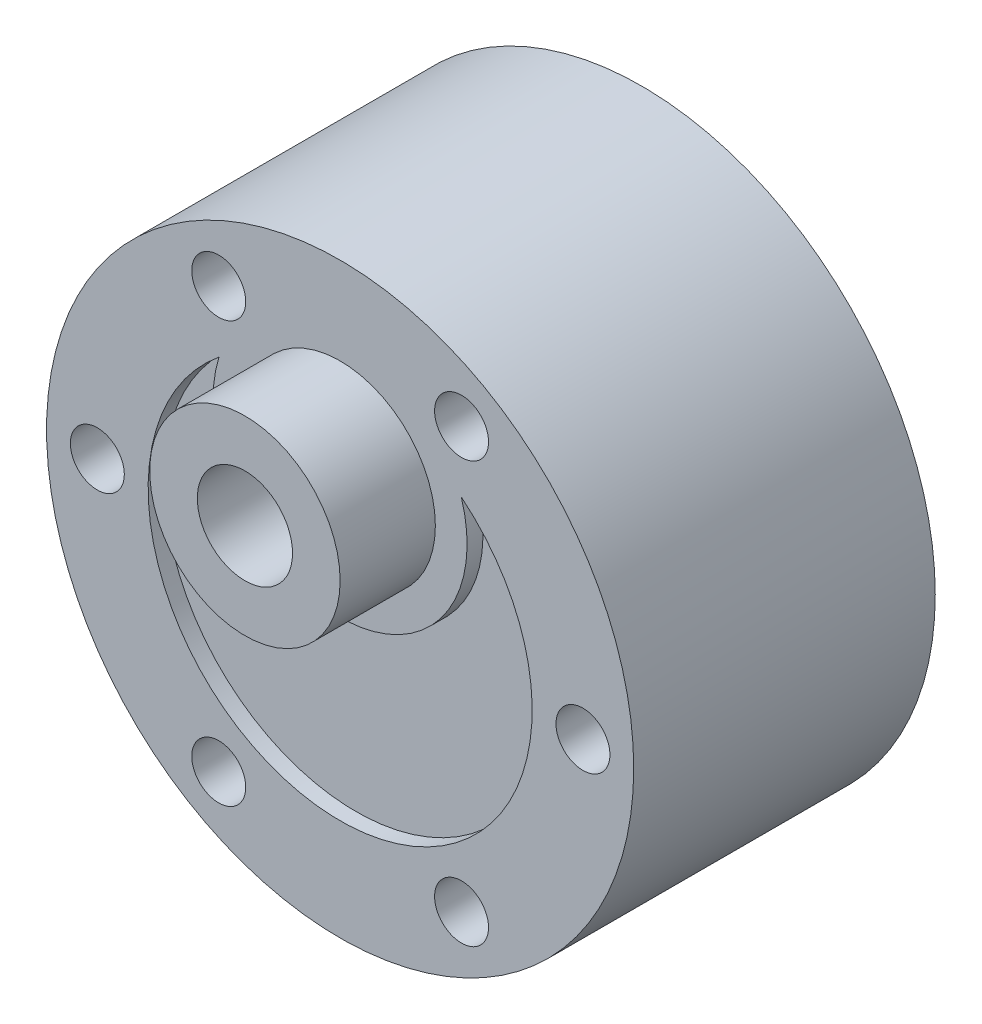
from build123d import *

# Parameters (mm, degrees)
SKETCH1_R                        = 18.5
BOSS_EXTRUDE1_DEPTH              = 19
SKETCH4_R                        = 6
BOSS_EXTRUDE4_DEPTH              = 6
CUT_EXTRUDE2_DEPTH               = 1
TALADRO_DE_MARGEN_PARA_M31_D     = 3.4
TALADRO_DE_MARGEN_PARA_M31_DEPTH = 6
TALADRO_DE_MARGEN_PARA_M31_TIP   = 1.021463052
CROQUIS1_R                       = 18
CORTAR_EXTRUIR2_DEPTH            = 12
CORTAR_EXTRUIR3_REACH            = 27
CROQUIS2_R                       = 3
CROQUIS2_R_2                     = 1.7
CROQUIS3_R                       = 18
SALIENTE_EXTRUIR1_DEPTH          = 0.5
SKETCH11_R                       = 2
CUT_EXTRUDE3_DEPTH               = 10
SKETCH12_W                       = 12.5
SKETCH12_H                       = 1.5
CUT_EXTRUDE4_DEPTH               = 0.15
SKETCH13_R                       = 6
CUT_EXTRUDE5_DEPTH               = 10
SKETCH14_R                       = 2.25
SKETCH14_R_2                     = 2
BOSS_EXTRUDE5_DEPTH              = 1


with BuildPart() as part:
    # Sketch1 → Boss-Extrude1 (new body)
    with BuildSketch(Plane.XY):
        Circle(SKETCH1_R)
    extrude(amount=BOSS_EXTRUDE1_DEPTH)

    # Sketch4 → Boss-Extrude4 (add)
    with BuildSketch(Plane.XY.offset(19)):
        with Locations((0, 7)):
            Circle(SKETCH4_R)
    extrude(amount=BOSS_EXTRUDE4_DEPTH)

    # Sketch8 → Cut-Extrude2 (cut)
    with BuildSketch(Plane.XY.offset(19)):
        with BuildLine():
            ThreePointArc((7.635768375, 9.386428571), (0, -12.1), (-7.635768375, 9.386428571))
            ThreePointArc((-7.635768375, 9.386428571), (0, -1), (7.635768375, 9.386428571))
        make_face()
    extrude(amount=-CUT_EXTRUDE2_DEPTH, mode=Mode.SUBTRACT)

    # Taladro de margen para M31
    with Locations(Plane.XY.offset(19)):
        with Locations((7.65, -13.250188678), (-7.65, -13.250188678), (-15.3, 0), (-7.65, 13.250188678), (15.3, 0), (7.65, 13.250188678)):
            Hole(TALADRO_DE_MARGEN_PARA_M31_D / 2, depth=TALADRO_DE_MARGEN_PARA_M31_DEPTH)
            with Locations((0, 0, -(TALADRO_DE_MARGEN_PARA_M31_DEPTH + TALADRO_DE_MARGEN_PARA_M31_TIP / 2))):  # 118° drill point
                Cone(0, TALADRO_DE_MARGEN_PARA_M31_D / 2, TALADRO_DE_MARGEN_PARA_M31_TIP, mode=Mode.SUBTRACT)

    # Croquis1 → Cortar-Extruir2 (cut)
    with BuildSketch(Plane(origin=(0, 0, 0), x_dir=(-1, 0, 0), z_dir=(0, 0, -1))):
        Circle(CROQUIS1_R)
    extrude(amount=-CORTAR_EXTRUIR2_DEPTH, mode=Mode.SUBTRACT)

    # Croquis2 → Cortar-Extruir3 (cut, up to next)
    with BuildSketch(Plane.XY.offset(25), mode=Mode.PRIVATE) as cortar_extruir3_sk1:
        with Locations((0, 7)):
            Circle(CROQUIS2_R)
    cortar_extruir3_tool1 = extrude(cortar_extruir3_sk1.sketch, amount=-CORTAR_EXTRUIR3_REACH, mode=Mode.PRIVATE) & part.part
    add(cortar_extruir3_tool1.solids().sort_by_distance((0, 7, 25))[0], mode=Mode.SUBTRACT)
    # Croquis2 → Cortar-Extruir3 (cut, up to next)
    with BuildSketch(Plane.XY.offset(25), mode=Mode.PRIVATE) as cortar_extruir3_sk2:
        with Locations((7.65, 13.250188678)):
            Circle(CROQUIS2_R_2)
    cortar_extruir3_tool2 = extrude(cortar_extruir3_sk2.sketch, amount=-CORTAR_EXTRUIR3_REACH, mode=Mode.PRIVATE) & part.part
    add(cortar_extruir3_tool2.solids().sort_by_distance((7.65, 13.250189, 25))[0], mode=Mode.SUBTRACT)

    # Croquis3 → Saliente-Extruir1 (add)
    with BuildSketch(Plane(origin=(0, 0, 0), x_dir=(-1, 0, 0), z_dir=(0, 0, -1))):
        Circle(CROQUIS3_R)
    extrude(amount=-SALIENTE_EXTRUIR1_DEPTH)

    # Sketch11 → Cut-Extrude3 (cut)
    with BuildSketch(Plane(origin=(0, 0, 0), x_dir=(-1, 0, 0), z_dir=(0, 0, -1))):
        Circle(SKETCH11_R)
    extrude(amount=-CUT_EXTRUDE3_DEPTH, mode=Mode.SUBTRACT)

    # Sketch12 → Cut-Extrude4 (cut)
    with BuildSketch(Plane(origin=(0, 0, 0), x_dir=(-1, 0, 0), z_dir=(0, 0, -1))):
        with Locations((0, -15)):
            Rectangle(SKETCH12_W, SKETCH12_H)
    extrude(amount=-CUT_EXTRUDE4_DEPTH, mode=Mode.SUBTRACT)

    # Sketch13 → Cut-Extrude5 (cut)
    with BuildSketch(Plane(origin=(0, 0, 0), x_dir=(-1, 0, 0), z_dir=(0, 0, -1))):
        Circle(SKETCH13_R)
    extrude(amount=-CUT_EXTRUDE5_DEPTH, mode=Mode.SUBTRACT)

    # Sketch14 → Boss-Extrude5 (add)
    with BuildSketch(Plane(origin=(0, 0, 12), x_dir=(-1, 0, 0), z_dir=(0, 0, -1))):
        with Locations((0, -5.15)):
            Circle(SKETCH14_R)
        with Locations((0, -5.15)):
            Circle(SKETCH14_R_2, mode=Mode.SUBTRACT)
    extrude(amount=BOSS_EXTRUDE5_DEPTH)


solid = part.part
